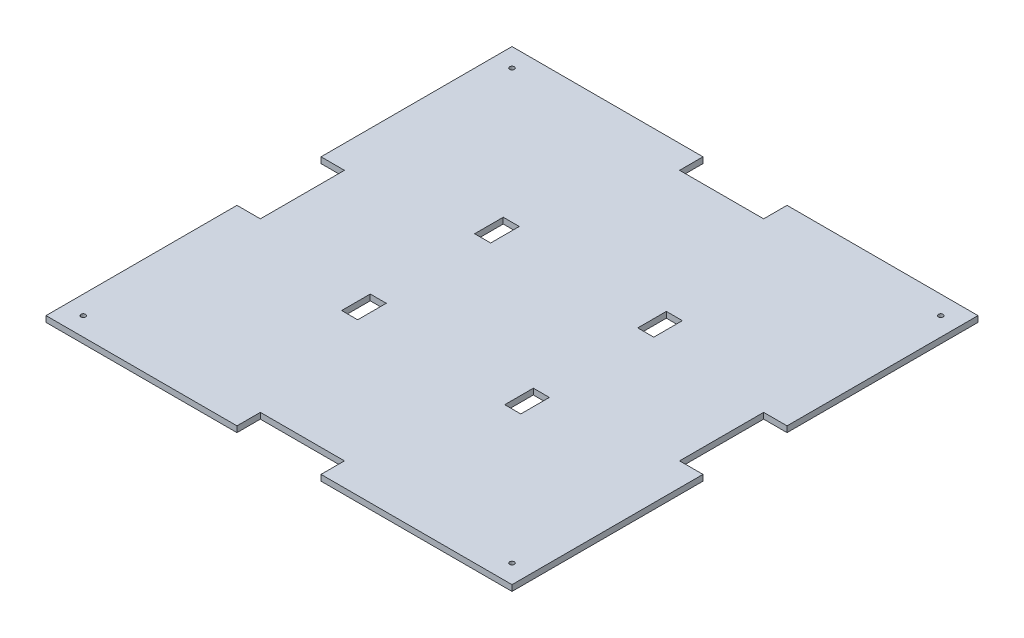
from build123d import *

# Parameters (mm, degrees)
SKETCH2_W           = 250
SKETCH2_H           = 250
BOSS_EXTRUDE1_DEPTH = 3.175
SKETCH3_W           = 8.6
SKETCH3_H           = 15.35
CUT_EXTRUDE1_DEPTH  = 10
SKETCH4_W           = 45.1
SKETCH4_H           = 25.1
SKETCH4_W_2         = 25.1
SKETCH4_H_2         = 45.1
CUT_EXTRUDE2_DEPTH  = 10
M3_TAPPED_HOLE1_D   = 2.5
M3_TAPPED_HOLE2_D   = 2.5


with BuildPart() as part:
    # Sketch2 → Boss-Extrude1 (new body)
    with BuildSketch(Plane(origin=(0, 0, 0), x_dir=(1, 0, 0), z_dir=(0, 1, 0))):
        Rectangle(SKETCH2_W, SKETCH2_H)
    extrude(amount=BOSS_EXTRUDE1_DEPTH)

    # Sketch3 → Cut-Extrude1 (cut)
    with BuildSketch(Plane(origin=(0, 3.175, 0), x_dir=(1, 0, 0), z_dir=(0, 1, 0))):
        with Locations((-43.75, 35.675)):
            Rectangle(SKETCH3_W, SKETCH3_H)
        with Locations((-43.75, -35.675)):
            Rectangle(SKETCH3_W, SKETCH3_H)
        with Locations((43.75, -35.675)):
            Rectangle(SKETCH3_W, SKETCH3_H)
        with Locations((43.75, 35.675)):
            Rectangle(SKETCH3_W, SKETCH3_H)
    extrude(amount=-CUT_EXTRUDE1_DEPTH, mode=Mode.SUBTRACT)

    # Sketch4 → Cut-Extrude2 (cut)
    with BuildSketch(Plane(origin=(0, 3.175, 0), x_dir=(1, 0, 0), z_dir=(0, 1, 0))):
        with Locations((0, 125)):
            Rectangle(SKETCH4_W, SKETCH4_H)
        with Locations((125, 0)):
            Rectangle(SKETCH4_W_2, SKETCH4_H_2)
        with Locations((0, -125)):
            Rectangle(SKETCH4_W, SKETCH4_H)
        with Locations((-125, 0)):
            Rectangle(SKETCH4_W_2, SKETCH4_H_2)
    extrude(amount=-CUT_EXTRUDE2_DEPTH, mode=Mode.SUBTRACT)

    # M3 Tapped Hole1 (through all)
    with Locations(Plane(origin=(0, 3.175, 0), x_dir=(1, 0, 0), z_dir=(0, 1, 0))):
        with Locations((-115, 115)):
            Hole(M3_TAPPED_HOLE1_D / 2)

    # M3 Tapped Hole2 (through all)
    with Locations(Plane(origin=(0, 3.175, 0), x_dir=(1, 0, 0), z_dir=(0, 1, 0))):
        with Locations((115, 115), (115, -115), (-115, -115)):
            Hole(M3_TAPPED_HOLE2_D / 2)


solid = part.part
